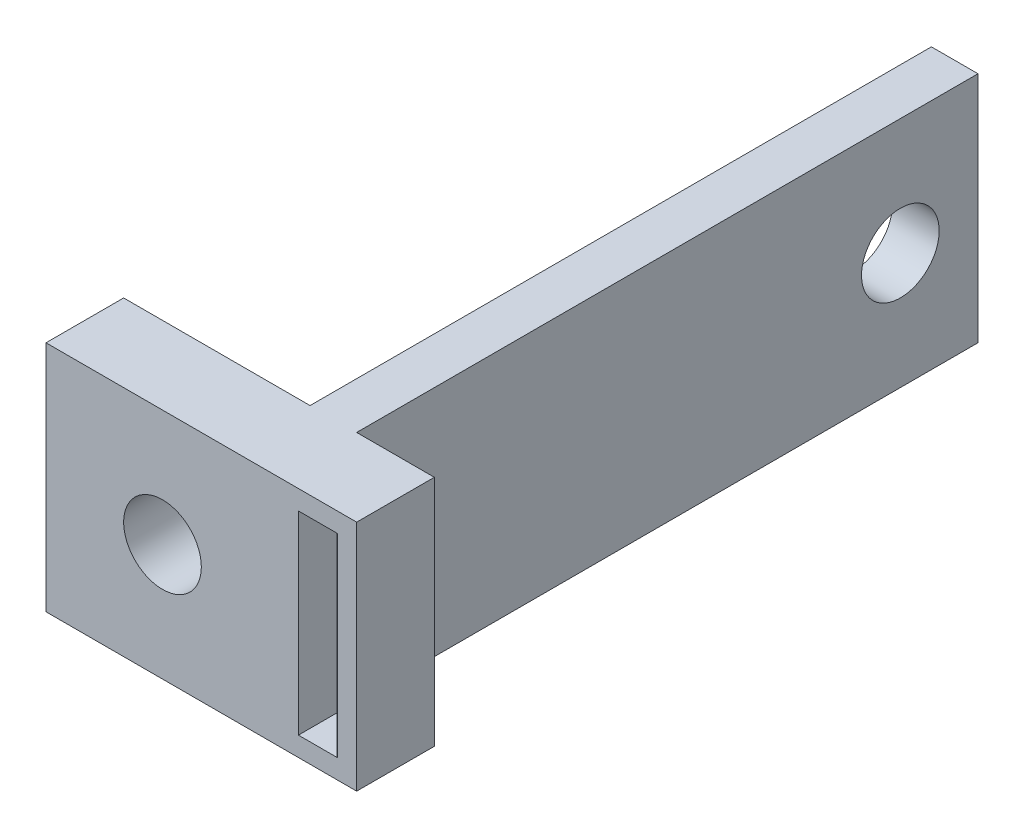
from build123d import *

# Parameters (mm, degrees)
SKETCH1_W           = 20
SKETCH1_H           = 15
BOSS_EXTRUDE1_DEPTH = 5
SKETCH2_R           = 2.5
CUT_EXTRUDE1_DEPTH  = 5
SKETCH3_W           = 3
SKETCH3_H           = 15
BOSS_EXTRUDE2_DEPTH = 40
SKETCH5_W           = 2.5
SKETCH5_H           = 12.5
CUT_EXTRUDE3_DEPTH  = 6
SKETCH4_R           = 2.5
CUT_EXTRUDE4_DEPTH  = 10


with BuildPart() as part:
    # Sketch1 → Boss-Extrude1 (new body)
    with BuildSketch(Plane.XY):
        with Locations((10, 7.5)):
            Rectangle(SKETCH1_W, SKETCH1_H)
    extrude(amount=BOSS_EXTRUDE1_DEPTH)

    # Sketch2 → Cut-Extrude1 (cut)
    with BuildSketch(Plane.XY.offset(5)):
        with Locations((7.5, 7.5)):
            Circle(SKETCH2_R)
    extrude(amount=-CUT_EXTRUDE1_DEPTH, mode=Mode.SUBTRACT)

    # Sketch3 → Boss-Extrude2 (add)
    with BuildSketch(Plane(origin=(0, 0, 0), x_dir=(-1, 0, 0), z_dir=(0, 0, -1))):
        with Locations((-13.5, 7.5)):
            Rectangle(SKETCH3_W, SKETCH3_H)
    extrude(amount=BOSS_EXTRUDE2_DEPTH)

    # Sketch5 → Cut-Extrude3 (cut, through all)
    with BuildSketch(Plane(origin=(0, 0, 0), x_dir=(-1, 0, 0), z_dir=(0, 0, -1))):
        with Locations((-17.5, 7.5)):
            Rectangle(SKETCH5_W, SKETCH5_H)
    extrude(amount=-CUT_EXTRUDE3_DEPTH, mode=Mode.SUBTRACT)

    # Sketch4 → Cut-Extrude4 (cut)
    with BuildSketch(Plane(origin=(15, 0, 0), x_dir=(0, 0, -1), z_dir=(1, 0, 0))):
        with Locations((35, 7.5)):
            Circle(SKETCH4_R)
    extrude(amount=-CUT_EXTRUDE4_DEPTH, mode=Mode.SUBTRACT)


solid = part.part
